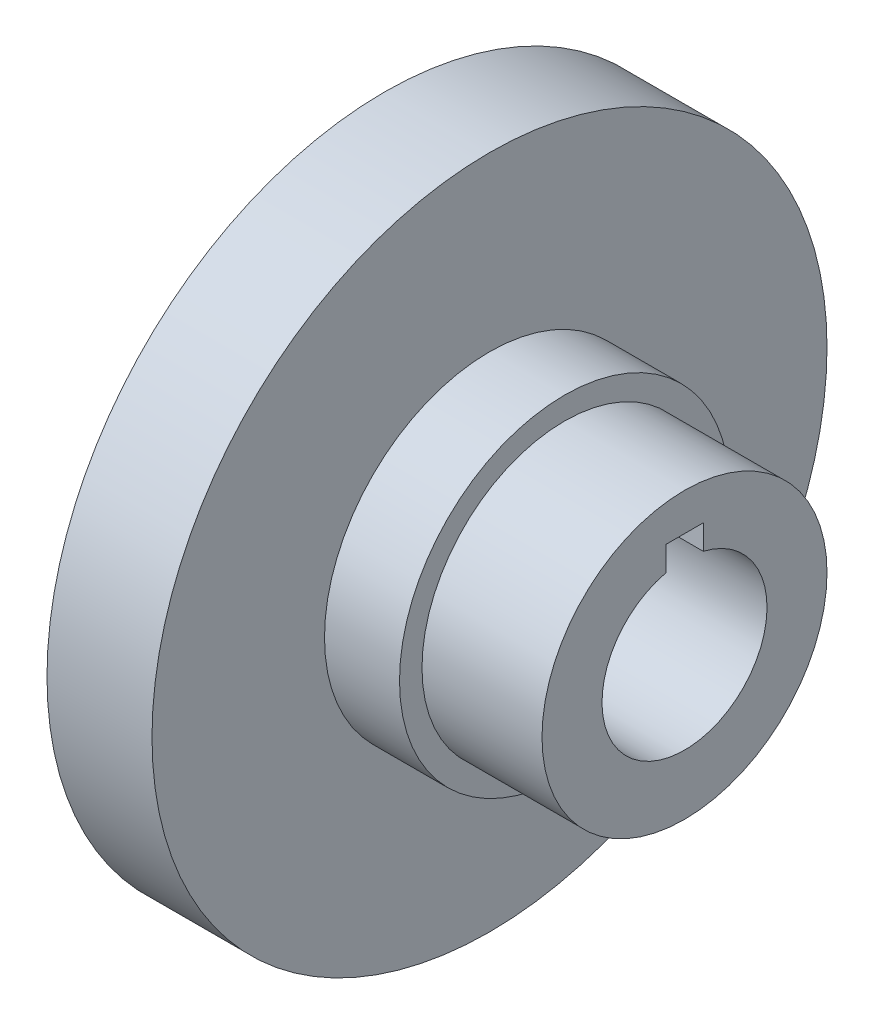
from build123d import *

# Parameters (mm, degrees)
SKETCH_1_R          = 45
EXTRUDE_1_DEPTH     = 14
SKETCH_2_R          = 22
EXTRUDE_2_DEPTH     = 10
SKETCH_3_R          = 19
EXTRUDE_3_DEPTH     = 16
SKETCH_4_R          = 23
CUT_EXTRUDE_1_DEPTH = 12
SKETCH_5_R          = 11
CUT_EXTRUDE_2_DEPTH = 29
SKETCH_6_W          = 28
SKETCH_6_H          = 14
CUT_EXTRUDE_3_DEPTH = 2.5
SKETCH_7_R          = 4
CUT_EXTRUDE_4_DEPTH = 12
FILLET_1_R          = 3


with BuildPart() as part:
    # 草图1 → 凸台-拉伸1 (new body)
    with BuildSketch(Plane(origin=(0, 0, 0), x_dir=(0, 0, -1), z_dir=(1, 0, 0))):
        Circle(SKETCH_1_R)
    extrude(amount=EXTRUDE_1_DEPTH)

    # 草图2 → 凸台-拉伸2 (add)
    with BuildSketch(Plane(origin=(14, 0, 0), x_dir=(0, 0, -1), z_dir=(1, 0, 0))):
        Circle(SKETCH_2_R)
    extrude(amount=EXTRUDE_2_DEPTH)

    # 草图3 → 凸台-拉伸3 (add)
    with BuildSketch(Plane(origin=(24, 0, 0), x_dir=(0, 0, -1), z_dir=(1, 0, 0))):
        Circle(SKETCH_3_R)
    extrude(amount=EXTRUDE_3_DEPTH)

    # 草图4 → 切除-拉伸1 (cut)
    with BuildSketch(Plane.ZY):
        Circle(SKETCH_4_R)
    extrude(amount=-CUT_EXTRUDE_1_DEPTH, mode=Mode.SUBTRACT)

    # 草图5 → 切除-拉伸2 (cut, through all)
    with BuildSketch(Plane.ZY.offset(-12)):
        Circle(SKETCH_5_R)
    extrude(amount=-CUT_EXTRUDE_2_DEPTH, mode=Mode.SUBTRACT)

    # 草图6 → 切除-拉伸3 (cut, symmetric)
    with BuildSketch(Plane.XY):
        with Locations((26, 7)):
            Rectangle(SKETCH_6_W, SKETCH_6_H)
    extrude(amount=CUT_EXTRUDE_3_DEPTH, both=True, mode=Mode.SUBTRACT)

    # 草图7 → 切除-拉伸4 (cut)
    with BuildSketch(Plane.ZY):
        with Locations((0, 34)):
            Circle(SKETCH_7_R)
        with Locations((34, 0)):
            Circle(SKETCH_7_R)
        with Locations((0, -34)):
            Circle(SKETCH_7_R)
        with BuildLine():
            ThreePointArc((-38, 0), (-34, -4), (-30, 0))
            Line((-30, 0), (-38, 0))
        make_face()
        with BuildLine():
            Line((-38, 0), (-30, 0))
            ThreePointArc((-30, 0), (-34, 4), (-38, 0))
        make_face()
    extrude(amount=-CUT_EXTRUDE_4_DEPTH, mode=Mode.SUBTRACT)

    # 圆角1
    fillet_1_edges = [part.edges().sort_by_distance(p)[0] for p in [
        (12, 0, -23),
    ]]
    fillet(fillet_1_edges, radius=FILLET_1_R)


solid = part.part
